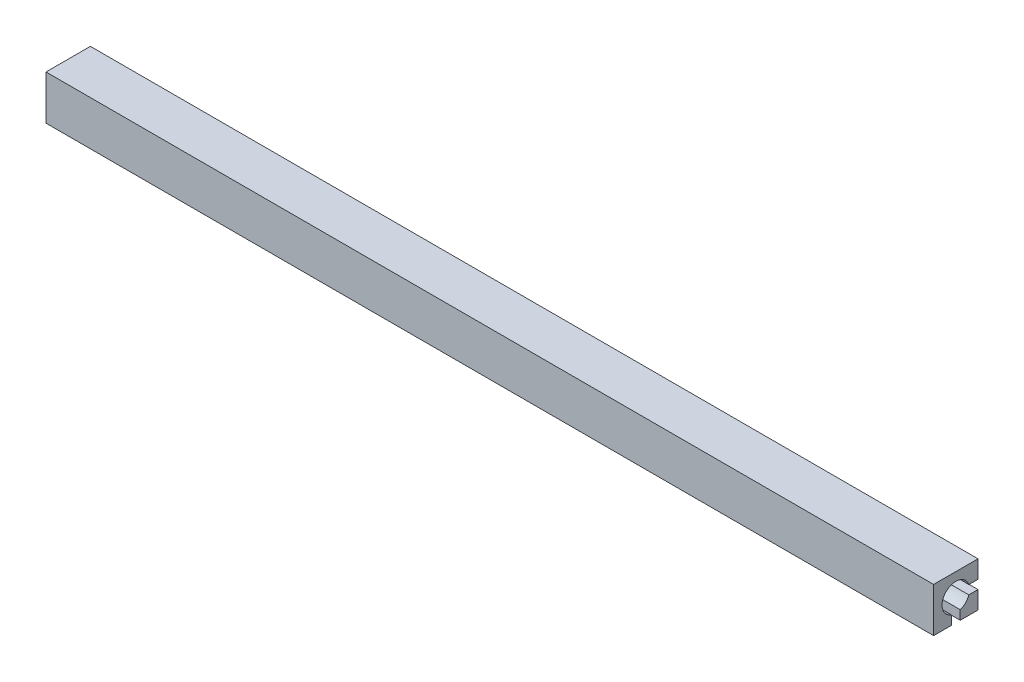
from build123d import *

# Parameters (mm, degrees)
CROQUIS2_W                   = 220
CROQUIS2_H                   = 220
CROQUIS2_W_2                 = 200
CROQUIS2_H_2                 = 200
SALIENTE_EXTRUIR1_DEPTH      = 10
CROQUIS3_W                   = 212
CROQUIS3_H                   = 212
CROQUIS3_W_2                 = 210
CROQUIS3_H_2                 = 210
CROQUIS3_W_3                 = 208
CROQUIS3_H_3                 = 208
CORTAR_EXTRUIR1_DEPTH        = 3.5
CROQUIS4_W                   = 10
CROQUIS4_H                   = 10
SALIENTE_EXTRUIR2_DEPTH      = 200
SALIENTE_EXTRUIR2_DEPTH_BACK = 10
CROQUIS6_W                   = 3.5
CROQUIS6_H                   = 2
CROQUIS6_W_2                 = 2
CROQUIS6_H_2                 = 3.5
CROQUIS6_W_3                 = 1.99805467
CORTAR_EXTRUIR2_DEPTH        = 203.5
CROQUIS7_W                   = 220
CROQUIS7_H                   = 220
CROQUIS7_W_2                 = 200
CROQUIS7_H_2                 = 200
SALIENTE_EXTRUIR3_DEPTH      = 10
CORTAR_EXTRUIR3_START        = -3.5
CROQUIS8_W                   = 207
CROQUIS8_H                   = 2
CORTAR_EXTRUIR3_DEPTH        = 207
MATRIZC1_COUNT               = 4
CROQUIS9_W                   = 86
CROQUIS9_H                   = 16
BRAZOS_DEPTH                 = 10
MATRIZC2_COUNT               = 4
CORTAR_EXTRUIR4_DEPTH        = 221
CORTAR_EXTRUIR6_DEPTH        = 11
CROQUIS12_R                  = 3.1
CORTAR_EXTRUIR7_DEPTH        = 10.2
CROQUIS13_R                  = 3.1
CORTAR_EXTRUIR8_DEPTH        = 10.2


with BuildPart() as part:
    # Croquis2 → Saliente-Extruir1 (new body)
    with BuildSketch(Plane.XY):
        with Locations((110, -110)):
            Rectangle(CROQUIS2_W, CROQUIS2_H)
        with Locations((110, -110)):
            Rectangle(CROQUIS2_W_2, CROQUIS2_H_2, mode=Mode.SUBTRACT)
    extrude(amount=SALIENTE_EXTRUIR1_DEPTH)

    # Croquis3 → Cortar-Extruir1 (cut)
    with BuildSketch(Plane.XY.offset(10)):
        with Locations((110, -110)):
            Rectangle(CROQUIS3_W, CROQUIS3_H)
        with Locations((110, -110)):
            Rectangle(CROQUIS3_W_2, CROQUIS3_H_2, mode=Mode.SUBTRACT)
        with Locations((110, -110)):
            Rectangle(CROQUIS3_W_2, CROQUIS3_H_2)
        with Locations((110, -110)):
            Rectangle(CROQUIS3_W_3, CROQUIS3_H_3, mode=Mode.SUBTRACT)
    extrude(amount=-CORTAR_EXTRUIR1_DEPTH, mode=Mode.SUBTRACT)

    # Croquis4 → Saliente-Extruir2 (add, two sides)
    with BuildSketch(Plane.XY.offset(10)) as saliente_extruir2_sk:
        with Locations((5, -5)):
            Rectangle(CROQUIS4_W, CROQUIS4_H)
        with Locations((215, -5)):
            Rectangle(CROQUIS4_W, CROQUIS4_H)
        with Locations((215, -215)):
            Rectangle(CROQUIS4_W, CROQUIS4_H)
        with Locations((5, -215)):
            Rectangle(CROQUIS4_W, CROQUIS4_H)
    extrude(amount=SALIENTE_EXTRUIR2_DEPTH)
    extrude(saliente_extruir2_sk.sketch, amount=-SALIENTE_EXTRUIR2_DEPTH_BACK)

    # Croquis6 → Cortar-Extruir2 (cut)
    with BuildSketch(Plane.XY.offset(210)):
        with Locations((8.25, -5)):
            Rectangle(CROQUIS6_W, CROQUIS6_H)
        with Locations((5, -8.25)):
            Rectangle(CROQUIS6_W_2, CROQUIS6_H_2)
        with Locations((211.75, -5)):
            Rectangle(CROQUIS6_W, CROQUIS6_H)
        with Locations((215, -8.25)):
            Rectangle(CROQUIS6_W_2, CROQUIS6_H_2)
        with Locations((211.75, -215)):
            Rectangle(CROQUIS6_W, CROQUIS6_H)
        with Locations((215.000972665, -211.75)):
            Rectangle(CROQUIS6_W_3, CROQUIS6_H_2)
        with Locations((5, -211.75)):
            Rectangle(CROQUIS6_W_2, CROQUIS6_H_2)
        with Locations((8.25, -215)):
            Rectangle(CROQUIS6_W, CROQUIS6_H)
    extrude(amount=-CORTAR_EXTRUIR2_DEPTH, mode=Mode.SUBTRACT)

    # Croquis7 → Saliente-Extruir3 (add)
    with BuildSketch(Plane.XY.offset(210)):
        with Locations((110, -110)):
            Rectangle(CROQUIS7_W, CROQUIS7_H)
        with Locations((110, -110)):
            Rectangle(CROQUIS7_W_2, CROQUIS7_H_2, mode=Mode.SUBTRACT)
    extrude(amount=SALIENTE_EXTRUIR3_DEPTH)

    # Croquis8 → Cortar-Extruir3 (cut)
    with BuildSketch(Plane(origin=(0, -210, 0), x_dir=(1, 0, 0), z_dir=(0, 1, 0)).offset(CORTAR_EXTRUIR3_START)):
        with Locations((110, -215)):
            Rectangle(CROQUIS8_W, CROQUIS8_H)
    cortar_extruir3 = extrude(amount=CORTAR_EXTRUIR3_DEPTH, mode=Mode.SUBTRACT)

    # MatrizC1: Cortar-Extruir3 ×4 about axis
    matrizc1_axis = Axis((0, -110, 110), (1, 0, 0))
    for i in range(1, MATRIZC1_COUNT):
        add(cortar_extruir3.rotate(matrizc1_axis, i * 360 / MATRIZC1_COUNT), mode=Mode.SUBTRACT)

    # Croquis9 → Brazos (add)
    with BuildSketch(Plane.XY.offset(220)):
        with Locations((43, -110)):
            Rectangle(CROQUIS9_W, CROQUIS9_H)
        with BuildLine():
            ThreePointArc((71.801526277, -112.25), (69.551526277, -110), (71.801526277, -107.75))
            Line((71.801526277, -107.75), (75, -107.75))
            ThreePointArc((75, -107.75), (77.25, -110), (75, -112.25))
            Line((75, -112.25), (71.801526277, -112.25))
        make_face(mode=Mode.SUBTRACT)
        with Locations((177, -110)):
            Rectangle(CROQUIS9_W, CROQUIS9_H)
        with BuildLine():
            Line((145, -107.75), (148.198473723, -107.75))
            ThreePointArc((148.198473723, -107.75), (150.448473723, -110), (148.198473723, -112.25))
            Line((148.198473723, -112.25), (145, -112.25))
            ThreePointArc((145, -112.25), (142.75, -110), (145, -107.75))
        make_face(mode=Mode.SUBTRACT)
    extrude(amount=-BRAZOS_DEPTH)

    # MatrizC2: Cortar-Extruir3 ×4 about axis
    matrizc2_axis = Axis((110, 0, 110), (0, 1, 0))
    for i in range(1, MATRIZC2_COUNT):
        add(cortar_extruir3.rotate(matrizc2_axis, i * 360 / MATRIZC2_COUNT), mode=Mode.SUBTRACT)

    # Croquis10 → Cortar-Extruir4 (cut, through all)
    with BuildSketch(Plane(origin=(0, 0, 0), x_dir=(1, 0, 0), z_dir=(0, 1, 0))):
        Polygon((210, -210), (-54.613887122, -210), (-54.613887122, 5.730335669), (210, 5.730335669), (296.699829043, 5.730335669), (296.699829043, -210), align=None)
    extrude(amount=-CORTAR_EXTRUIR4_DEPTH, mode=Mode.SUBTRACT)

    # Croquis11 → Cortar-Extruir6 (cut, through all)
    with BuildSketch(Plane.XY.offset(220)):
        Polygon((225.348159566, -10), (300.018724731, -10), (300.018724731, -229.853044827), (10, -229.853044827), (-53.650825238, -229.853044827), (-53.650825238, -10), (-6.520912183, -10), (-6.520912183, 9.079623398), (10, 9.079623398), (10, -10), (210, -10), (210, 9.87282219), (225.348159566, 9.87282219), align=None)
    extrude(amount=-CORTAR_EXTRUIR6_DEPTH, mode=Mode.SUBTRACT)

    # Croquis12 → Cortar-Extruir7 (cut)
    with BuildSketch(Plane.ZY.offset(-10)):
        with Locations((215, -5)):
            Circle(CROQUIS12_R)
    extrude(amount=-CORTAR_EXTRUIR7_DEPTH, mode=Mode.SUBTRACT)

    # Croquis13 → Cortar-Extruir8 (cut)
    with BuildSketch(Plane(origin=(210, 0, 0), x_dir=(0, 0, -1), z_dir=(1, 0, 0))):
        with Locations((-215, -5)):
            Circle(CROQUIS13_R)
    extrude(amount=-CORTAR_EXTRUIR8_DEPTH, mode=Mode.SUBTRACT)


solid = part.part
